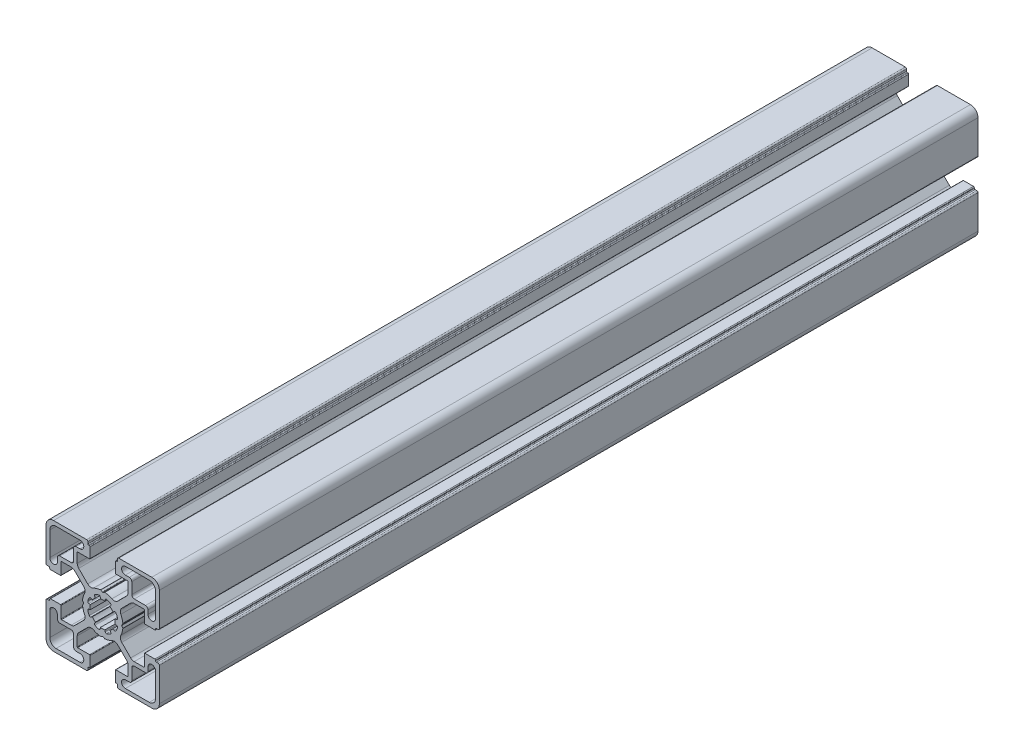
from build123d import *

# Parameters (mm, degrees)
BOSS_EXTRU_1_DEPTH = 325


with BuildPart() as part:
    # Esquisse2 → Boss.-Extru.1 (new body)
    with BuildSketch(Plane.XY):
        with BuildLine():
            Line((-192.464705439, -351.135013575), (-192.030789329, -350.389251613))
            ThreePointArc((-192.030789329, -350.389251613), (-192.008099493, -350.33058749), (-192.004751867, -350.267777448))
            ThreePointArc((-192.004751867, -350.267777448), (-192.285035172, -348.883447185), (-192.804402464, -347.569983587))
            ThreePointArc((-192.804402464, -347.569983587), (-192.985908697, -346.38788866), (-192.44128198, -345.323147062))
            Line((-192.44128198, -345.323147062), (-188.874986025, -341.756855105))
            ThreePointArc((-188.874986025, -341.756855105), (-188.244141301, -341.335338521), (-187.500009401, -341.187321592))
            Line((-187.500009401, -341.187321592), (-183.687863463, -341.187321592))
            ThreePointArc((-183.687863463, -341.187321592), (-183.546441859, -341.245900338), (-183.487863113, -341.387321941))
            Line((-183.487863113, -341.387321941), (-183.487863113, -345.981828905))
            ThreePointArc((-183.487863113, -345.981828905), (-183.429284366, -346.12325051), (-183.287862762, -346.181829256))
            Line((-183.287862762, -346.181829256), (-179.285166009, -346.181829256))
            ThreePointArc((-179.285166009, -346.181829256), (-179.073034487, -346.093961503), (-178.985166733, -345.88182998))
            Line((-178.985166733, -345.88182998), (-178.985166733, -345.681839032))
            ThreePointArc((-178.985166733, -345.681839032), (-178.897298833, -345.469707156), (-178.685166958, -345.381839256))
            Line((-178.685166958, -345.381839256), (-178.0047864, -345.381839256))
            ThreePointArc((-178.0047864, -345.381839256), (-177.651233276, -345.235392756), (-177.504786776, -344.881839631))
            Line((-177.504786776, -344.881839631), (-177.504786776, -331.681827015))
            ThreePointArc((-177.504786776, -331.681827015), (-178.383465776, -329.560508257), (-180.504784534, -328.681829257))
            Line((-180.504784534, -328.681829257), (-193.629056903, -328.681829257))
            ThreePointArc((-193.629056903, -328.681829257), (-193.982610029, -328.828275756), (-194.129056529, -329.181828882))
            Line((-194.129056529, -329.181828882), (-194.129056529, -329.881829981))
            ThreePointArc((-194.129056529, -329.881829981), (-194.216924283, -330.093961503), (-194.429055805, -330.181829256))
            Line((-194.429055805, -330.181829256), (-194.70476714, -330.181829256))
            ThreePointArc((-194.70476714, -330.181829256), (-194.916898308, -330.269696863), (-195.004765915, -330.481828031))
            Line((-195.004765915, -330.481828031), (-195.004765915, -334.515030698))
            ThreePointArc((-195.004765915, -334.515030698), (-194.946187022, -334.656452656), (-194.804765065, -334.715031549))
            Line((-194.804765065, -334.715031549), (-190.099380697, -334.715031549))
            ThreePointArc((-190.099380697, -334.715031549), (-189.957959093, -334.773610295), (-189.899380347, -334.9150319))
            Line((-189.899380347, -334.9150319), (-189.899380347, -338.710260175))
            ThreePointArc((-189.899380347, -338.710260175), (-190.051621327, -339.47562727), (-190.48516696, -340.124474162))
            Line((-190.48516696, -340.124474162), (-194.059867926, -343.699175128))
            ThreePointArc((-194.059867926, -343.699175128), (-195.150164081, -344.214009408), (-196.338266679, -344.008553194))
            ThreePointArc((-196.338266679, -344.008553194), (-197.695629231, -343.467994797), (-199.128369878, -343.181829256))
            ThreePointArc((-199.128369878, -343.181829256), (-199.191201005, -343.184754557), (-199.250016338, -343.207049503))
            Line((-199.250016338, -343.207049503), (-199.892137456, -343.574906197))
            ThreePointArc((-199.892137456, -343.574906197), (-199.941802013, -343.622754392), (-200.004765916, -343.650889155))
            ThreePointArc((-200.004765916, -343.650889155), (-200.067729818, -343.622754392), (-200.117394375, -343.574906197))
            Line((-200.117394375, -343.574906197), (-200.759515492, -343.207049503))
            ThreePointArc((-200.759515492, -343.207049503), (-200.818330825, -343.184754557), (-200.881161953, -343.181829255))
            ThreePointArc((-200.881161953, -343.181829255), (-202.3139026, -343.467994797), (-203.671265152, -344.008553193))
            ThreePointArc((-203.671265152, -344.008553193), (-204.85936775, -344.214009407), (-205.949663904, -343.699175128))
            Line((-205.949663904, -343.699175128), (-209.52436487, -340.124474162))
            ThreePointArc((-209.52436487, -340.124474162), (-209.957910503, -339.475627269), (-210.110151485, -338.710260174))
            Line((-210.110151485, -338.710260174), (-210.110151485, -334.915031899))
            ThreePointArc((-210.110151485, -334.915031899), (-210.051572738, -334.773610295), (-209.910151134, -334.715031548))
            Line((-209.910151134, -334.715031548), (-205.204766766, -334.715031548))
            ThreePointArc((-205.204766766, -334.715031548), (-205.063344808, -334.656452656), (-205.004765915, -334.515030698))
            Line((-205.004765915, -334.515030698), (-205.004765915, -330.481828032))
            ThreePointArc((-205.004765915, -330.481828032), (-205.092633523, -330.269696863), (-205.304764692, -330.181829256))
            Line((-205.304764692, -330.181829256), (-205.580476025, -330.181829256))
            ThreePointArc((-205.580476025, -330.181829256), (-205.792607548, -330.093961502), (-205.880475302, -329.88182998))
            Line((-205.880475302, -329.88182998), (-205.880475302, -329.181828882))
            ThreePointArc((-205.880475302, -329.181828882), (-206.026921801, -328.828275756), (-206.380474927, -328.681829256))
            Line((-206.380474927, -328.681829256), (-219.504747296, -328.681829256))
            ThreePointArc((-219.504747296, -328.681829256), (-221.626066055, -329.560508256), (-222.504745055, -331.681827014))
            Line((-222.504745055, -331.681827014), (-222.504745055, -344.88183963))
            ThreePointArc((-222.504745055, -344.88183963), (-222.358298555, -345.235392756), (-222.00474543, -345.381839256))
            Line((-222.00474543, -345.381839256), (-221.324364871, -345.381839256))
            ThreePointArc((-221.324364871, -345.381839256), (-221.112232996, -345.469707157), (-221.024365096, -345.681839032))
            Line((-221.024365096, -345.681839032), (-221.024365096, -345.88182998))
            ThreePointArc((-221.024365096, -345.88182998), (-220.936497342, -346.093961503), (-220.724365819, -346.181829256))
            Line((-220.724365819, -346.181829256), (-216.721669067, -346.181829256))
            ThreePointArc((-216.721669067, -346.181829256), (-216.580247463, -346.12325051), (-216.521668717, -345.981828906))
            Line((-216.521668717, -345.981828906), (-216.521668717, -341.387321942))
            ThreePointArc((-216.521668717, -341.387321942), (-216.46308997, -341.245900338), (-216.321668366, -341.187321592))
            Line((-216.321668366, -341.187321592), (-212.509522428, -341.187321592))
            ThreePointArc((-212.509522428, -341.187321592), (-211.765390527, -341.335338522), (-211.134545803, -341.756855106))
            Line((-211.134545803, -341.756855106), (-207.568249848, -345.323147062))
            ThreePointArc((-207.568249848, -345.323147062), (-207.023623131, -346.38788866), (-207.205129364, -347.569983588))
            ThreePointArc((-207.205129364, -347.569983588), (-207.724496656, -348.883447186), (-208.004779961, -350.267777448))
            ThreePointArc((-208.004779961, -350.267777448), (-208.001432335, -350.33058749), (-207.978742499, -350.389251614))
            Line((-207.978742499, -350.389251614), (-207.54482639, -351.135013575))
            ThreePointArc((-207.54482639, -351.135013575), (-207.5390619, -351.158167493), (-207.536095855, -351.181843132))
            ThreePointArc((-207.536095855, -351.181843132), (-207.5390619, -351.20551877), (-207.54482639, -351.228672687))
            Line((-207.54482639, -351.228672687), (-207.978742499, -351.974434649))
            ThreePointArc((-207.978742499, -351.974434649), (-208.001432335, -352.033098773), (-208.004779962, -352.095908815))
            ThreePointArc((-208.004779962, -352.095908815), (-207.724496656, -353.480239077), (-207.205129364, -354.793702675))
            ThreePointArc((-207.205129364, -354.793702675), (-207.023623132, -355.975797603), (-207.568249848, -357.040539202))
            Line((-207.568249848, -357.040539202), (-211.134545804, -360.606831158))
            ThreePointArc((-211.134545804, -360.606831158), (-211.765390528, -361.028347742), (-212.509522429, -361.176364671))
            Line((-212.509522429, -361.176364671), (-216.321668366, -361.176364671))
            ThreePointArc((-216.321668366, -361.176364671), (-216.463089971, -361.117785925), (-216.521668717, -360.97636432))
            Line((-216.521668717, -360.97636432), (-216.521668717, -356.381857357))
            ThreePointArc((-216.521668717, -356.381857357), (-216.580247463, -356.240435753), (-216.721669067, -356.181857007))
            Line((-216.721669067, -356.181857007), (-220.72436582, -356.181857007))
            ThreePointArc((-220.72436582, -356.181857007), (-220.936497342, -356.26972476), (-221.024365096, -356.481856283))
            Line((-221.024365096, -356.481856283), (-221.024365096, -356.68184723))
            ThreePointArc((-221.024365096, -356.68184723), (-221.112232996, -356.893979106), (-221.324364871, -356.981847005))
            Line((-221.324364871, -356.981847005), (-222.004745429, -356.981847005))
            ThreePointArc((-222.004745429, -356.981847005), (-222.358298555, -357.128293506), (-222.504745055, -357.481846632))
            Line((-222.504745055, -357.481846632), (-222.504745055, -370.681859247))
            ThreePointArc((-222.504745055, -370.681859247), (-221.626066055, -372.803178006), (-219.504747296, -373.681857006))
            Line((-219.504747296, -373.681857006), (-206.380474927, -373.681857006))
            ThreePointArc((-206.380474927, -373.681857006), (-206.026921801, -373.535410506), (-205.880475301, -373.18185738))
            Line((-205.880475301, -373.18185738), (-205.880475301, -372.481856282))
            ThreePointArc((-205.880475301, -372.481856282), (-205.792607548, -372.269724759), (-205.580476025, -372.181857005))
            Line((-205.580476025, -372.181857005), (-205.304764691, -372.181857005))
            ThreePointArc((-205.304764691, -372.181857005), (-205.092633522, -372.093989398), (-205.004765915, -371.881858229))
            Line((-205.004765915, -371.881858229), (-205.004765915, -367.848655563))
            ThreePointArc((-205.004765915, -367.848655563), (-205.063344808, -367.707233605), (-205.204766766, -367.648654712))
            Line((-205.204766766, -367.648654712), (-209.910151134, -367.648654712))
            ThreePointArc((-209.910151134, -367.648654712), (-210.051572738, -367.590075966), (-210.110151485, -367.448654362))
            Line((-210.110151485, -367.448654362), (-210.110151485, -363.653426086))
            ThreePointArc((-210.110151485, -363.653426086), (-209.957910503, -362.888058992), (-209.524364871, -362.239212099))
            Line((-209.524364871, -362.239212099), (-205.949663905, -358.664511133))
            ThreePointArc((-205.949663905, -358.664511133), (-204.85936775, -358.149676855), (-203.671265152, -358.355133067))
            ThreePointArc((-203.671265152, -358.355133067), (-202.3139026, -358.895691464), (-200.881161954, -359.181857005))
            ThreePointArc((-200.881161954, -359.181857005), (-200.818330826, -359.178931703), (-200.759515493, -359.156636757))
            Line((-200.759515493, -359.156636757), (-200.117394376, -358.788780064))
            ThreePointArc((-200.117394376, -358.788780064), (-200.067729819, -358.740931869), (-200.004765916, -358.712797106))
            ThreePointArc((-200.004765916, -358.712797106), (-199.941802013, -358.740931869), (-199.892137456, -358.788780064))
            Line((-199.892137456, -358.788780064), (-199.250016339, -359.156636758))
            ThreePointArc((-199.250016339, -359.156636758), (-199.191201006, -359.178931704), (-199.128369878, -359.181857005))
            ThreePointArc((-199.128369878, -359.181857005), (-197.695629231, -358.895691464), (-196.338266679, -358.355133068))
            ThreePointArc((-196.338266679, -358.355133068), (-195.150164082, -358.149676855), (-194.059867927, -358.664511133))
            Line((-194.059867927, -358.664511133), (-190.48516696, -362.239212099))
            ThreePointArc((-190.48516696, -362.239212099), (-190.051621328, -362.888058992), (-189.899380348, -363.653426086))
            Line((-189.899380348, -363.653426086), (-189.899380348, -367.448654362))
            ThreePointArc((-189.899380348, -367.448654362), (-189.957959094, -367.590075965), (-190.099380697, -367.648654712))
            Line((-190.099380697, -367.648654712), (-194.804765066, -367.648654712))
            ThreePointArc((-194.804765066, -367.648654712), (-194.946187023, -367.707233605), (-195.004765916, -367.848655563))
            Line((-195.004765916, -367.848655563), (-195.004765916, -371.881858229))
            ThreePointArc((-195.004765916, -371.881858229), (-194.916898309, -372.093989397), (-194.70476714, -372.181857004))
            Line((-194.70476714, -372.181857004), (-194.429055806, -372.181857004))
            ThreePointArc((-194.429055806, -372.181857004), (-194.216924283, -372.269724758), (-194.12905653, -372.48185628))
            Line((-194.12905653, -372.48185628), (-194.12905653, -373.181857379))
            ThreePointArc((-194.12905653, -373.181857379), (-193.98261003, -373.535410505), (-193.629056903, -373.681857006))
            Line((-193.629056903, -373.681857006), (-180.504784534, -373.681857006))
            ThreePointArc((-180.504784534, -373.681857006), (-178.383465775, -372.803178005), (-177.504786775, -370.681859246))
            Line((-177.504786775, -370.681859246), (-177.504786775, -357.481846631))
            ThreePointArc((-177.504786775, -357.481846631), (-177.651233275, -357.128293504), (-178.004786402, -356.981847004))
            Line((-178.004786402, -356.981847004), (-178.685166959, -356.981847004))
            ThreePointArc((-178.685166959, -356.981847004), (-178.897298836, -356.893979105), (-178.985166735, -356.681847228))
            Line((-178.985166735, -356.681847228), (-178.985166735, -356.481856281))
            ThreePointArc((-178.985166735, -356.481856281), (-179.073034488, -356.269724759), (-179.28516601, -356.181857005))
            Line((-179.28516601, -356.181857005), (-183.287862762, -356.181857005))
            ThreePointArc((-183.287862762, -356.181857005), (-183.429284367, -356.240435752), (-183.487863113, -356.381857356))
            Line((-183.487863113, -356.381857356), (-183.487863113, -360.97636432))
            ThreePointArc((-183.487863113, -360.97636432), (-183.546441859, -361.117785924), (-183.687863463, -361.176364671))
            Line((-183.687863463, -361.176364671), (-187.500009401, -361.176364671))
            ThreePointArc((-187.500009401, -361.176364671), (-188.244141302, -361.028347742), (-188.874986026, -360.606831157))
            Line((-188.874986026, -360.606831157), (-192.441281982, -357.040539201))
            ThreePointArc((-192.441281982, -357.040539201), (-192.985908698, -355.975797602), (-192.804402465, -354.793702674))
            ThreePointArc((-192.804402465, -354.793702674), (-192.285035173, -353.480239077), (-192.004751867, -352.095908814))
            ThreePointArc((-192.004751867, -352.095908814), (-192.008099493, -352.033098772), (-192.030789329, -351.974434649))
            Line((-192.030789329, -351.974434649), (-192.464705438, -351.228672687))
            ThreePointArc((-192.464705438, -351.228672687), (-192.47046993, -351.20551877), (-192.473435973, -351.181843131))
            ThreePointArc((-192.473435973, -351.181843131), (-192.47046993, -351.158167492), (-192.464705439, -351.135013575))
        make_face()
        with BuildLine():
            Line((-195.08422015, -352.069665956), (-194.515035218, -352.16805429))
            ThreePointArc((-194.515035218, -352.16805429), (-194.165013852, -352.386136153), (-194.09791825, -352.793042574))
            ThreePointArc((-194.09791825, -352.793042574), (-194.353505931, -353.535154011), (-194.702268027, -354.238303673))
            ThreePointArc((-194.702268027, -354.238303673), (-195.035805071, -354.480613812), (-195.437988264, -354.390005633))
            Line((-195.437988264, -354.390005633), (-195.915053025, -354.058342475))
            ThreePointArc((-195.915053025, -354.058342475), (-196.474632965, -354.722769754), (-197.140765494, -355.280318651))
            Line((-197.140765494, -355.280318651), (-196.813454008, -355.744441346))
            ThreePointArc((-196.813454008, -355.744441346), (-196.720150548, -356.146118205), (-196.960380945, -356.481288596))
            ThreePointArc((-196.960380945, -356.481288596), (-197.665869942, -356.825320826), (-198.409694498, -357.075915978))
            ThreePointArc((-198.409694498, -357.075915978), (-198.816910196, -357.011432294), (-199.037244235, -356.662956066))
            Line((-199.037244235, -356.662956066), (-199.137377178, -356.106032077))
            ThreePointArc((-199.137377178, -356.106032077), (-200.004765915, -356.181843131), (-200.872154653, -356.106032077))
            Line((-200.872154653, -356.106032077), (-200.972287596, -356.662956066))
            ThreePointArc((-200.972287596, -356.662956066), (-201.192621634, -357.011432294), (-201.599837332, -357.075915978))
            ThreePointArc((-201.599837332, -357.075915978), (-202.343661888, -356.825320826), (-203.049150885, -356.481288596))
            ThreePointArc((-203.049150885, -356.481288596), (-203.289381283, -356.146118205), (-203.196077822, -355.744441346))
            Line((-203.196077822, -355.744441346), (-202.868766337, -355.280318651))
            ThreePointArc((-202.868766337, -355.280318651), (-203.534898866, -354.722769754), (-204.094478805, -354.058342475))
            Line((-204.094478805, -354.058342475), (-204.571543566, -354.390005633))
            ThreePointArc((-204.571543566, -354.390005633), (-204.97372676, -354.480613812), (-205.307263804, -354.238303673))
            ThreePointArc((-205.307263804, -354.238303673), (-205.6560259, -353.535154011), (-205.91161358, -352.793042574))
            ThreePointArc((-205.91161358, -352.793042574), (-205.844517979, -352.386136153), (-205.494496613, -352.16805429))
            Line((-205.494496613, -352.16805429), (-204.925311681, -352.069665956))
            ThreePointArc((-204.925311681, -352.069665956), (-205.004765916, -351.18184313), (-204.925311681, -350.294020305))
            Line((-204.925311681, -350.294020305), (-205.494496613, -350.195631971))
            ThreePointArc((-205.494496613, -350.195631971), (-205.844517979, -349.977550108), (-205.91161358, -349.570643686))
            ThreePointArc((-205.91161358, -349.570643686), (-205.6560259, -348.82853225), (-205.307263804, -348.125382588))
            ThreePointArc((-205.307263804, -348.125382588), (-204.97372676, -347.883072448), (-204.571543566, -347.973680627))
            Line((-204.571543566, -347.973680627), (-204.094478805, -348.305343785))
            ThreePointArc((-204.094478805, -348.305343785), (-203.534898866, -347.640916506), (-202.868766337, -347.08336761))
            Line((-202.868766337, -347.08336761), (-203.196077822, -346.619244915))
            ThreePointArc((-203.196077822, -346.619244915), (-203.289381283, -346.217568056), (-203.049150885, -345.882397665))
            ThreePointArc((-203.049150885, -345.882397665), (-202.343661888, -345.538365434), (-201.599837332, -345.287770282))
            ThreePointArc((-201.599837332, -345.287770282), (-201.192621634, -345.352253967), (-200.972287596, -345.700730195))
            Line((-200.972287596, -345.700730195), (-200.872154653, -346.257654184))
            ThreePointArc((-200.872154653, -346.257654184), (-200.004765915, -346.18184313), (-199.137377178, -346.257654184))
            Line((-199.137377178, -346.257654184), (-199.037244235, -345.700730195))
            ThreePointArc((-199.037244235, -345.700730195), (-198.816910196, -345.352253967), (-198.409694498, -345.287770282))
            ThreePointArc((-198.409694498, -345.287770282), (-197.665869942, -345.538365434), (-196.960380945, -345.882397665))
            ThreePointArc((-196.960380945, -345.882397665), (-196.720150548, -346.217568056), (-196.813454008, -346.619244915))
            Line((-196.813454008, -346.619244915), (-197.140765494, -347.08336761))
            ThreePointArc((-197.140765494, -347.08336761), (-196.474632965, -347.640916506), (-195.915053025, -348.305343785))
            Line((-195.915053025, -348.305343785), (-195.437988264, -347.973680627))
            ThreePointArc((-195.437988264, -347.973680627), (-195.035805071, -347.883072448), (-194.702268027, -348.125382588))
            ThreePointArc((-194.702268027, -348.125382588), (-194.353505931, -348.82853225), (-194.09791825, -349.570643686))
            ThreePointArc((-194.09791825, -349.570643686), (-194.165013852, -349.977550108), (-194.515035218, -350.195631971))
            Line((-194.515035218, -350.195631971), (-195.08422015, -350.294020305))
            ThreePointArc((-195.08422015, -350.294020305), (-195.004765915, -351.18184313), (-195.08422015, -352.069665956))
        make_face(mode=Mode.SUBTRACT)
        with BuildLine():
            Line((-191.004786777, -330.181829255), (-181.504784909, -330.181829255))
            ThreePointArc((-181.504784909, -330.181829255), (-179.737019277, -330.914061756), (-179.004786777, -332.681827388))
            Line((-179.004786777, -332.681827388), (-179.004786777, -342.181638256))
            ThreePointArc((-179.004786777, -342.181638256), (-180.504786777, -343.681638255), (-182.004786777, -342.181638255))
            Line((-182.004786777, -342.181638255), (-182.004786777, -340.631829508))
            ThreePointArc((-182.004786777, -340.631829508), (-182.297679777, -339.924723255), (-183.00478603, -339.631830255))
            Line((-183.00478603, -339.631830255), (-187.454788523, -339.631830255))
            ThreePointArc((-187.454788523, -339.631830255), (-188.161894777, -339.338937255), (-188.454787777, -338.631831002))
            Line((-188.454787777, -338.631831002), (-188.454787777, -334.181828508))
            ThreePointArc((-188.454787777, -334.181828508), (-188.747680777, -333.474722255), (-189.45478703, -333.181829255))
            Line((-189.45478703, -333.181829255), (-191.004786777, -333.181829255))
            ThreePointArc((-191.004786777, -333.181829255), (-192.504786777, -331.681829255), (-191.004786777, -330.181829255))
        make_face(mode=Mode.SUBTRACT)
        with BuildLine():
            Line((-221.004745053, -332.681827388), (-221.004745053, -342.181638256))
            ThreePointArc((-221.004745053, -342.181638256), (-219.504745053, -343.681638255), (-218.004745054, -342.181638255))
            Line((-218.004745054, -342.181638255), (-218.004745054, -340.631829508))
            ThreePointArc((-218.004745054, -340.631829508), (-217.711852054, -339.924723255), (-217.0047458, -339.631830255))
            Line((-217.0047458, -339.631830255), (-212.554743307, -339.631830255))
            ThreePointArc((-212.554743307, -339.631830255), (-211.847637054, -339.338937255), (-211.554744054, -338.631831002))
            Line((-211.554744054, -338.631831002), (-211.554744054, -334.181828508))
            ThreePointArc((-211.554744054, -334.181828508), (-211.261851054, -333.474722255), (-210.554744801, -333.181829255))
            Line((-210.554744801, -333.181829255), (-209.004745053, -333.181829255))
            ThreePointArc((-209.004745053, -333.181829255), (-207.504745054, -331.681829255), (-209.004745053, -330.181829255))
            Line((-209.004745053, -330.181829255), (-218.504746922, -330.181829255))
            ThreePointArc((-218.504746922, -330.181829255), (-220.272512554, -330.914061756), (-221.004745053, -332.681827388))
        make_face(mode=Mode.SUBTRACT)
        with BuildLine():
            Line((-191.004786777, -372.181857005), (-181.504784909, -372.181857005))
            ThreePointArc((-181.504784909, -372.181857005), (-179.737019277, -371.449624505), (-179.004786777, -369.681858873))
            Line((-179.004786777, -369.681858873), (-179.004786777, -360.182048004))
            ThreePointArc((-179.004786777, -360.182048004), (-180.504786777, -358.682048005), (-182.004786777, -360.182048005))
            Line((-182.004786777, -360.182048005), (-182.004786777, -361.731856752))
            ThreePointArc((-182.004786777, -361.731856752), (-182.297679777, -362.438963006), (-183.00478603, -362.731856006))
            Line((-183.00478603, -362.731856006), (-187.454788523, -362.731856006))
            ThreePointArc((-187.454788523, -362.731856006), (-188.161894777, -363.024749005), (-188.454787777, -363.731855258))
            Line((-188.454787777, -363.731855258), (-188.454787777, -368.181857752))
            ThreePointArc((-188.454787777, -368.181857752), (-188.747680777, -368.888964005), (-189.45478703, -369.181857005))
            Line((-189.45478703, -369.181857005), (-191.004786777, -369.181857005))
            ThreePointArc((-191.004786777, -369.181857005), (-192.504786777, -370.681857005), (-191.004786777, -372.181857005))
        make_face(mode=Mode.SUBTRACT)
        with BuildLine():
            Line((-209.004745053, -372.181857005), (-218.504746922, -372.181857005))
            ThreePointArc((-218.504746922, -372.181857005), (-220.272512554, -371.449624505), (-221.004745053, -369.681858873))
            Line((-221.004745053, -369.681858873), (-221.004745053, -360.182048004))
            ThreePointArc((-221.004745053, -360.182048004), (-219.504745053, -358.682048005), (-218.004745054, -360.182048005))
            Line((-218.004745054, -360.182048005), (-218.004745054, -361.731856752))
            ThreePointArc((-218.004745054, -361.731856752), (-217.711852054, -362.438963006), (-217.0047458, -362.731856006))
            Line((-217.0047458, -362.731856006), (-212.554743307, -362.731856006))
            ThreePointArc((-212.554743307, -362.731856006), (-211.847637054, -363.024749005), (-211.554744054, -363.731855258))
            Line((-211.554744054, -363.731855258), (-211.554744054, -368.181857752))
            ThreePointArc((-211.554744054, -368.181857752), (-211.261851054, -368.888964005), (-210.554744801, -369.181857005))
            Line((-210.554744801, -369.181857005), (-209.004745053, -369.181857005))
            ThreePointArc((-209.004745053, -369.181857005), (-207.504745054, -370.681857005), (-209.004745053, -372.181857005))
        make_face(mode=Mode.SUBTRACT)
    extrude(amount=BOSS_EXTRU_1_DEPTH)


solid = part.part
